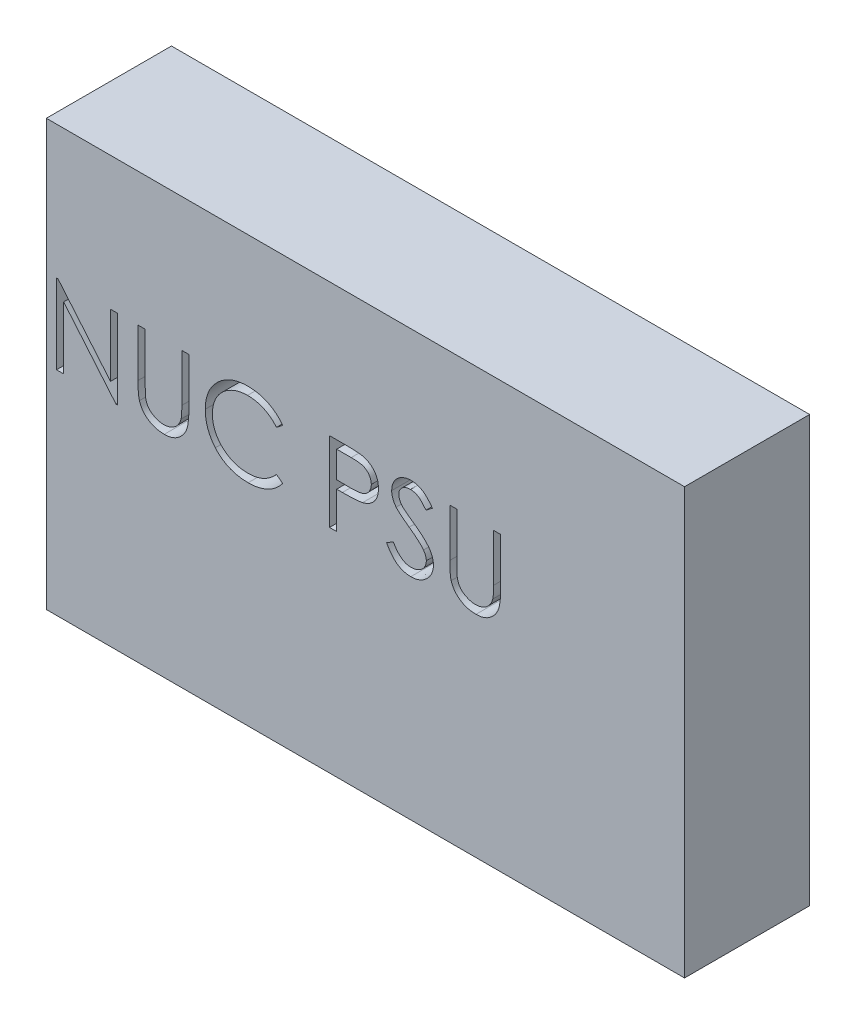
from build123d import *

# Parameters (mm, degrees)
SKETCH1_W               = 102
SKETCH1_H               = 68
BOSS_EXTRUDE1_DEPTH     = 20
CUT_EXTRUDE1_DEPTH      = 1
CUT_EXTRUDE1_DEPTH_BACK = 21


with BuildPart() as part:
    # Sketch1 → Boss-Extrude1 (new body)
    with BuildSketch(Plane.XY):
        Rectangle(SKETCH1_W, SKETCH1_H)
    extrude(amount=BOSS_EXTRUDE1_DEPTH)

    # Sketch2 → Cut-Extrude1 (cut, two sides)
    with BuildSketch(Plane.XY.offset(20)) as cut_extrude1_sk:
        Polygon((-49.371794872, 0), (-49.371794872, 12.7), (-49.132652244, 12.7), (-40.742307692, 2.704346955), (-40.742307692, 12.7), (-39.602564103, 12.7), (-39.602564103, 0), (-39.862059295, 0), (-48.232051282, 9.97275641), (-48.232051282, 0), align=None)
        with BuildLine():
            Line((-36.346153846, 12.7), (-35.206410256, 12.7))
            Line((-35.206410256, 12.7), (-35.206410256, 5.090685096))
            add(Edge.make_bspline(
                [(-35.206410256, 5.090685096), (-35.20657987, 4.982986426), (-35.206901742, 4.778609641), (-35.204751763, 4.487713236), (-35.198730626, 4.229096028), (-35.194934561, 4.001761138), (-35.186489665, 3.80675174), (-35.179602467, 3.643011327), (-35.170746732, 3.511315221), (-35.160103706, 3.434458718), (-35.155528846, 3.401422276)],
                knots=[0, 0, 0, 0, 0.000323097, 0.000613132, 0.000872677, 0.001099157, 0.001295199, 0.001458198, 0.00159088, 0.001690911, 0.001690911, 0.001690911, 0.001690911], degree=3))
            add(Edge.make_bspline(
                [(-35.155528846, 3.401422276), (-35.136742067, 3.282235449), (-35.100227077, 3.050577546), (-35.007167363, 2.720710352), (-34.877201002, 2.423416203), (-34.72319339, 2.14941809), (-34.520237915, 1.906342412), (-34.277110801, 1.682417272), (-33.982551469, 1.486576723), (-33.655034414, 1.307503778), (-33.302027981, 1.163576193), (-32.9413071, 1.054743128), (-32.578294005, 0.988416835), (-32.335266206, 0.980736822), (-32.214583333, 0.976923077)],
                knots=[0, 0, 0, 0, 0.000361804, 0.000703222, 0.001024581, 0.001333516, 0.001642649, 0.00197037, 0.002321784, 0.002700859, 0.003088736, 0.003463025, 0.003829839, 0.00419167, 0.00419167, 0.00419167, 0.00419167], degree=3))
            add(Edge.make_bspline(
                [(-32.214583333, 0.976923077), (-32.110974047, 0.980819619), (-31.904353894, 0.988590199), (-31.597353417, 1.036710249), (-31.298358737, 1.123435158), (-31.005893412, 1.235339425), (-30.731751269, 1.383194969), (-30.475779351, 1.553994873), (-30.247310218, 1.75433148), (-30.038819769, 1.976038444), (-29.85726443, 2.226191433), (-29.699889145, 2.499343534), (-29.570980771, 2.79960545), (-29.507322838, 3.010622925), (-29.474619391, 3.119030449)],
                knots=[0, 0, 0, 0, 0.000310887, 0.000619979, 0.000929248, 0.001243418, 0.001557536, 0.001861656, 0.002164646, 0.002467059, 0.002772877, 0.003089693, 0.003411052, 0.003750569, 0.003750569, 0.003750569, 0.003750569], degree=3))
            add(Edge.make_bspline(
                [(-29.474619391, 3.119030449), (-29.463733222, 3.163838133), (-29.439474451, 3.26368771), (-29.416806602, 3.432493536), (-29.393197209, 3.631663514), (-29.37681577, 3.862628663), (-29.360845627, 4.124615049), (-29.351291334, 4.418987469), (-29.346875243, 4.744677013), (-29.345559232, 4.971960429), (-29.344871795, 5.090685096)],
                knots=[0, 0, 0, 0, 0.000138249, 0.000308074, 0.000510355, 0.000740013, 0.001002497, 0.001297784, 0.001623465, 0.001979644, 0.001979644, 0.001979644, 0.001979644], degree=3))
            Line((-29.344871795, 5.090685096), (-29.344871795, 12.7))
            Line((-29.344871795, 12.7), (-28.205128205, 12.7))
            Line((-28.205128205, 12.7), (-28.205128205, 5.029627404))
            add(Edge.make_bspline(
                [(-28.205128205, 5.029627404), (-28.206050299, 4.891384715), (-28.207849822, 4.621595701), (-28.223454771, 4.226257913), (-28.248335884, 3.851234238), (-28.283489804, 3.496474265), (-28.330069786, 3.163247458), (-28.381868444, 2.848633014), (-28.447834178, 2.554889297), (-28.524881091, 2.279725953), (-28.612959394, 2.017795662), (-28.727045846, 1.76920726), (-28.855586175, 1.526403581), (-29.008039344, 1.293057015), (-29.179349218, 1.068134379), (-29.373302459, 0.852999736), (-29.583484415, 0.644215196), (-29.813389102, 0.447136356), (-30.059226723, 0.266402014), (-30.320265997, 0.107478674), (-30.594501705, -0.026864167), (-30.881220991, -0.137448235), (-31.180546213, -0.220595495), (-31.492484918, -0.282553918), (-31.817747134, -0.317759397), (-32.038961744, -0.322991544), (-32.150981571, -0.325641026)],
                knots=[0, 0, 0, 0, 0.000414715, 0.000809341, 0.001186722, 0.001542137, 0.001878541, 0.00219599, 0.002498424, 0.002781137, 0.003053079, 0.003326374, 0.003600686, 0.003876597, 0.004161544, 0.004448032, 0.004744861, 0.005049778, 0.005355596, 0.005659269, 0.00596533, 0.006270545, 0.006579814, 0.006896139, 0.007223722, 0.007559781, 0.007559781, 0.007559781, 0.007559781], degree=3))
            add(Edge.make_bspline(
                [(-32.150981571, -0.325641026), (-32.273152314, -0.322793449), (-32.512850876, -0.317206513), (-32.866049006, -0.285192534), (-33.204646233, -0.224891503), (-33.532218701, -0.148111136), (-33.844306676, -0.042215861), (-34.14509146, 0.081511621), (-34.429421532, 0.233466251), (-34.70190957, 0.402533706), (-34.955273685, 0.59276025), (-35.187855691, 0.800097452), (-35.400039564, 1.021223965), (-35.588248833, 1.258533863), (-35.755601757, 1.510181486), (-35.899765675, 1.776878727), (-36.023548018, 2.058522332), (-36.087434704, 2.254295373), (-36.119731571, 2.353265224)],
                knots=[0, 0, 0, 0, 0.000366567, 0.000719203, 0.001062587, 0.001397642, 0.001727489, 0.002050195, 0.002372249, 0.002693427, 0.003011436, 0.003321374, 0.003627277, 0.003929636, 0.004228811, 0.00453276, 0.004838091, 0.005150256, 0.005150256, 0.005150256, 0.005150256], degree=3))
            add(Edge.make_bspline(
                [(-36.119731571, 2.353265224), (-36.138517259, 2.420874852), (-36.179263835, 2.567521639), (-36.222898486, 2.81022404), (-36.259580011, 3.08967817), (-36.294071608, 3.405903157), (-36.314424113, 3.759144101), (-36.33226739, 4.149247882), (-36.34627955, 4.5766862), (-36.346196919, 4.874426871), (-36.346153846, 5.029627404)],
                knots=[0, 0, 0, 0, 0.000210421, 0.000456408, 0.000738845, 0.001056039, 0.001410405, 0.001800055, 0.002227648, 0.00269322, 0.00269322, 0.00269322, 0.00269322], degree=3))
            Line((-36.346153846, 5.029627404), (-36.346153846, 12.7))
        make_face()
        with BuildLine():
            Line((-13.225641026, 10.36963141), (-14.222916667, 9.606410256))
            add(Edge.make_bspline(
                [(-14.222916667, 9.606410256), (-14.294058033, 9.691195347), (-14.435381626, 9.859622441), (-14.662745018, 10.096131074), (-14.899696693, 10.317710737), (-15.146146076, 10.525416986), (-15.406529167, 10.711986393), (-15.674538351, 10.887141538), (-15.954656972, 11.044141615), (-16.342013266, 11.234507308), (-16.848735458, 11.433157642), (-17.486619589, 11.599720795), (-18.152502717, 11.705751919), (-18.60679115, 11.717235772), (-18.837860577, 11.723076923)],
                knots=[0, 0, 0, 0, 0.00033196, 0.000659444, 0.000983431, 0.001304932, 0.001625525, 0.001943778, 0.002265016, 0.002588143, 0.003238217, 0.003893566, 0.004562806, 0.005255583, 0.005255583, 0.005255583, 0.005255583], degree=3))
            add(Edge.make_bspline(
                [(-18.837860577, 11.723076923), (-18.965162835, 11.721611116), (-19.218585865, 11.718693107), (-19.594681754, 11.680197138), (-19.963754826, 11.626090747), (-20.325565003, 11.545807432), (-20.679651738, 11.444306785), (-21.028329883, 11.323020283), (-21.366551202, 11.172961293), (-21.698994524, 11.007105607), (-22.017507661, 10.819771736), (-22.318878834, 10.615434716), (-22.602008889, 10.396381138), (-22.867121796, 10.16178998), (-23.11448858, 9.912717724), (-23.342316822, 9.64650997), (-23.549818168, 9.364017797), (-23.741105659, 9.06896629), (-23.912420434, 8.762214875), (-24.055857425, 8.442628191), (-24.182876011, 8.115679017), (-24.283384692, 7.777673376), (-24.362939367, 7.430989626), (-24.417831174, 7.074697338), (-24.455889341, 6.709540843), (-24.45879284, 6.46203848), (-24.46025641, 6.337279647)],
                knots=[0, 0, 0, 0, 0.000381746, 0.00075995, 0.001133062, 0.001500343, 0.001870765, 0.002237676, 0.002606812, 0.002979993, 0.003351741, 0.00371443, 0.004071661, 0.004424911, 0.004775707, 0.005123948, 0.005475039, 0.005826461, 0.006178335, 0.006527846, 0.006876532, 0.007229865, 0.007584733, 0.007942761, 0.008310834, 0.008684951, 0.008684951, 0.008684951, 0.008684951], degree=3))
            add(Edge.make_bspline(
                [(-24.46025641, 6.337279647), (-24.45567781, 6.149568858), (-24.446688335, 5.781023622), (-24.36668438, 5.241198835), (-24.245108763, 4.72405239), (-24.062897955, 4.232816962), (-23.838220258, 3.761435206), (-23.55431861, 3.317882795), (-23.225510032, 2.895456975), (-22.847142852, 2.504141136), (-22.432013177, 2.146677047), (-21.986613612, 1.831896366), (-21.512053482, 1.569496649), (-21.013572567, 1.351143929), (-20.487334954, 1.183298089), (-19.934286957, 1.06513684), (-19.355631431, 0.988058071), (-18.96022818, 0.980678689), (-18.758994391, 0.976923077)],
                knots=[0, 0, 0, 0, 0.000562815, 0.001105012, 0.001633818, 0.00215373, 0.002673724, 0.003197432, 0.003730267, 0.004277248, 0.00482748, 0.005371661, 0.005910344, 0.006451519, 0.007001839, 0.007564217, 0.008146414, 0.008749794, 0.008749794, 0.008749794, 0.008749794], degree=3))
            add(Edge.make_bspline(
                [(-18.758994391, 0.976923077), (-18.53727892, 0.983050935), (-18.100889833, 0.995112025), (-17.460925852, 1.097289872), (-16.848293216, 1.262962888), (-16.262958974, 1.494821063), (-15.706573257, 1.796229394), (-15.178265376, 2.161618835), (-14.677589391, 2.594465071), (-14.376522167, 2.924966708), (-14.222916667, 3.093589744)],
                knots=[0, 0, 0, 0, 0.000664826, 0.001308536, 0.001938654, 0.00256556, 0.003192755, 0.00383282, 0.004489298, 0.005173128, 0.005173128, 0.005173128, 0.005173128], degree=3))
            Line((-14.222916667, 3.093589744), (-13.225641026, 2.338000801))
            add(Edge.make_bspline(
                [(-13.225641026, 2.338000801), (-13.305898167, 2.23444699), (-13.466028023, 2.027835384), (-13.725318542, 1.736563752), (-13.998467593, 1.462591966), (-14.287504026, 1.208128883), (-14.58910287, 0.96808268), (-14.908679546, 0.749273177), (-15.242032892, 0.548646254), (-15.58803343, 0.364942843), (-15.94631354, 0.201957403), (-16.316443918, 0.06242516), (-16.696829149, -0.057770867), (-17.087486622, -0.156656466), (-17.489226654, -0.233840114), (-17.900599517, -0.285437219), (-18.322493064, -0.320786452), (-18.607123364, -0.324008318), (-18.751362179, -0.325641026)],
                knots=[0, 0, 0, 0, 0.00039295, 0.000784017, 0.001168988, 0.001552873, 0.001938676, 0.002324679, 0.002713864, 0.003105353, 0.00349929, 0.003893826, 0.004291304, 0.004695459, 0.005102104, 0.005517692, 0.005938765, 0.006371376, 0.006371376, 0.006371376, 0.006371376], degree=3))
            add(Edge.make_bspline(
                [(-18.751362179, -0.325641026), (-18.887954914, -0.324690367), (-19.158050133, -0.322810557), (-19.556825603, -0.292358978), (-19.945044939, -0.25081279), (-20.321598581, -0.188255743), (-20.688541405, -0.114434852), (-21.042546954, -0.015479149), (-21.387098718, 0.095370684), (-21.720812411, 0.225654493), (-22.043971893, 0.372670355), (-22.355534866, 0.538828297), (-22.655358035, 0.722731064), (-22.946389133, 0.920324958), (-23.224328937, 1.137956882), (-23.491586015, 1.372604385), (-23.749659, 1.623476595), (-23.909325885, 1.804378492), (-23.989603365, 1.895332532)],
                knots=[0, 0, 0, 0, 0.000409666, 0.000810065, 0.001199174, 0.001580615, 0.001954827, 0.00232143, 0.002682661, 0.003040299, 0.003395496, 0.003747176, 0.004098847, 0.004450261, 0.004801913, 0.005157073, 0.005516877, 0.005880706, 0.005880706, 0.005880706, 0.005880706], degree=3))
            add(Edge.make_bspline(
                [(-23.989603365, 1.895332532), (-24.118184129, 2.053324846), (-24.373793316, 2.367402052), (-24.700820797, 2.876439756), (-24.980756211, 3.407910114), (-25.207091695, 3.964605284), (-25.384030755, 4.545276089), (-25.506608235, 5.150215241), (-25.5862612, 5.778857774), (-25.595369962, 6.206436979), (-25.6, 6.423778045)],
                knots=[0, 0, 0, 0, 0.000610709, 0.001214046, 0.001811469, 0.002410515, 0.003014109, 0.003629806, 0.004260284, 0.004912063, 0.004912063, 0.004912063, 0.004912063], degree=3))
            add(Edge.make_bspline(
                [(-25.6, 6.423778045), (-25.594356869, 6.652216405), (-25.583254361, 7.101654617), (-25.488926761, 7.76123439), (-25.337184272, 8.39315518), (-25.121658419, 8.996237339), (-24.848407573, 9.573652928), (-24.510853859, 10.120991014), (-24.112918801, 10.641751972), (-23.657723341, 11.12803407), (-23.158550438, 11.572676864), (-22.623993599, 11.963859375), (-22.055099106, 12.28940579), (-21.45813433, 12.561534722), (-20.828629143, 12.770701774), (-20.167926632, 12.917126194), (-19.477268284, 13.008265445), (-19.006053196, 13.019786913), (-18.766626603, 13.025641026)],
                knots=[0, 0, 0, 0, 0.000685036, 0.001347765, 0.001994424, 0.002631723, 0.003265569, 0.003907406, 0.004557186, 0.005228594, 0.005902557, 0.006560016, 0.007211953, 0.007865497, 0.008525192, 0.009197944, 0.009893113, 0.01061119, 0.01061119, 0.01061119, 0.01061119], degree=3))
            add(Edge.make_bspline(
                [(-18.766626603, 13.025641026), (-18.620705519, 13.023891553), (-18.331869428, 13.020428647), (-17.904595518, 12.986660646), (-17.488607646, 12.930368418), (-17.083619226, 12.85374725), (-16.687660018, 12.758652112), (-16.303756287, 12.634771601), (-15.929655338, 12.493124759), (-15.567716557, 12.329989754), (-15.219676503, 12.146867578), (-14.885643576, 11.94578803), (-14.568271089, 11.727000393), (-14.265325839, 11.492365442), (-13.981875587, 11.236919241), (-13.709872508, 10.967687964), (-13.458553738, 10.676916659), (-13.303420717, 10.472247328), (-13.225641026, 10.36963141)],
                knots=[0, 0, 0, 0, 0.000437698, 0.00086638, 0.001284824, 0.001696468, 0.002102476, 0.002505573, 0.002905769, 0.003302024, 0.003695764, 0.004084948, 0.004470952, 0.004851611, 0.005233595, 0.005614968, 0.005999089, 0.006385327, 0.006385327, 0.006385327, 0.006385327], degree=3))
        make_face()
        with BuildLine():
            Line((-5.735897436, 12.7), (-3.245252404, 12.7))
            add(Edge.make_bspline(
                [(-3.245252404, 12.7), (-3.073944259, 12.699811691), (-2.745710245, 12.699450882), (-2.2750299, 12.688511661), (-1.847548874, 12.673900522), (-1.46418892, 12.653646223), (-1.123770507, 12.629710024), (-0.82783402, 12.596138339), (-0.574053344, 12.561085266), (-0.421992799, 12.525447591), (-0.352644231, 12.509194712)],
                knots=[0, 0, 0, 0, 0.000513909, 0.000984672, 0.001412348, 0.001797041, 0.002136358, 0.002435846, 0.002690583, 0.002904164, 0.002904164, 0.002904164, 0.002904164], degree=3))
            add(Edge.make_bspline(
                [(-0.352644231, 12.509194712), (-0.264856265, 12.485166494), (-0.091348948, 12.437676253), (0.158663408, 12.342557885), (0.396530219, 12.229774028), (0.623067588, 12.101235732), (0.835491718, 11.951428113), (1.036971924, 11.786423843), (1.225730138, 11.602413294), (1.400704903, 11.401460324), (1.561395454, 11.18693842), (1.699751732, 10.955645185), (1.815601956, 10.711473885), (1.914964112, 10.454594355), (1.986477647, 10.182849467), (2.040350683, 9.898127396), (2.074544989, 9.600458663), (2.077819999, 9.39704143), (2.079487179, 9.293489583)],
                knots=[0, 0, 0, 0, 0.000272928, 0.000539425, 0.000801167, 0.00106213, 0.001319735, 0.001580002, 0.001842671, 0.002109519, 0.002378686, 0.002645705, 0.002916526, 0.003188682, 0.003470718, 0.003758119, 0.004057607, 0.004368151, 0.004368151, 0.004368151, 0.004368151], degree=3))
            add(Edge.make_bspline(
                [(2.079487179, 9.293489583), (2.07795801, 9.189067365), (2.074966086, 8.984758241), (2.039056708, 8.685862696), (1.990687155, 8.400227394), (1.916312137, 8.128485674), (1.818900694, 7.872251307), (1.704629531, 7.627608551), (1.566803578, 7.398719455), (1.408435196, 7.184753057), (1.232262268, 6.985508519), (1.039030178, 6.802429693), (0.829519031, 6.636588236), (0.604394665, 6.487612361), (0.361462356, 6.358956718), (0.104406542, 6.243723069), (-0.1690071, 6.14694522), (-0.358209937, 6.09603614), (-0.454407051, 6.070152244)],
                knots=[0, 0, 0, 0, 0.000313086, 0.000612574, 0.000902017, 0.001181599, 0.001456135, 0.001723565, 0.001990583, 0.002256192, 0.00252113, 0.002787469, 0.003053674, 0.003321805, 0.003596116, 0.003877417, 0.00416629, 0.004465075, 0.004465075, 0.004465075, 0.004465075], degree=3))
            add(Edge.make_bspline(
                [(-0.454407051, 6.070152244), (-0.533971949, 6.053232284), (-0.708343048, 6.016151208), (-0.995518069, 5.974754807), (-1.329874183, 5.939421228), (-1.710955028, 5.912928528), (-2.13841854, 5.89024862), (-2.612495959, 5.872221536), (-3.134117896, 5.862316067), (-3.497959268, 5.86180519), (-3.687920673, 5.861538462)],
                knots=[0, 0, 0, 0, 0.000243979, 0.000534694, 0.000869865, 0.0012525, 0.001680517, 0.002154049, 0.002675683, 0.00324556, 0.00324556, 0.00324556, 0.00324556], degree=3))
            Line((-3.687920673, 5.861538462), (-4.596153846, 5.861538462))
            Line((-4.596153846, 5.861538462), (-4.596153846, 0))
            Line((-4.596153846, 0), (-5.735897436, 0))
            Line((-5.735897436, 0), (-5.735897436, 12.7))
        make_face()
        with BuildLine():
            Line((-4.596153846, 11.397435897), (-4.596153846, 7.164102564))
            Line((-4.596153846, 7.164102564), (-2.372636218, 7.136117788))
            add(Edge.make_bspline(
                [(-2.372636218, 7.136117788), (-2.26406963, 7.136061678), (-2.05448407, 7.135953357), (-1.751729775, 7.150414025), (-1.470844646, 7.167107387), (-1.212691473, 7.191549166), (-0.977153882, 7.226097729), (-0.763839134, 7.260974606), (-0.574401279, 7.311431208), (-0.352698461, 7.379369202), (-0.105653172, 7.495238978), (0.163106218, 7.663422865), (0.390873775, 7.877801435), (0.587971594, 8.118839566), (0.744384351, 8.386987835), (0.858887523, 8.67389512), (0.926165437, 8.976619031), (0.935186769, 9.183767421), (0.93974359, 9.288401442)],
                knots=[0, 0, 0, 0, 0.000325651, 0.000628662, 0.000909076, 0.001169816, 0.001406195, 0.001623278, 0.001817645, 0.001993849, 0.002318305, 0.00263304, 0.002940915, 0.003252021, 0.003564434, 0.003868203, 0.004175604, 0.004489361, 0.004489361, 0.004489361, 0.004489361], degree=3))
            add(Edge.make_bspline(
                [(0.93974359, 9.288401442), (0.935161987, 9.390504048), (0.926054327, 9.593471392), (0.858360195, 9.890937181), (0.74460697, 10.174821022), (0.586921613, 10.439609075), (0.395546656, 10.679779878), (0.173117611, 10.88841231), (-0.079841937, 11.05613106), (-0.315148376, 11.164383254), (-0.524158394, 11.230478682), (-0.705702934, 11.276724245), (-0.910683381, 11.31364716), (-1.139166467, 11.343544784), (-1.389381264, 11.369138772), (-1.663477435, 11.386505032), (-1.960416655, 11.396670316), (-2.166557869, 11.397174525), (-2.273417468, 11.397435897)],
                knots=[0, 0, 0, 0, 0.000306146, 0.00060858, 0.000909985, 0.001220206, 0.001529716, 0.001828533, 0.002131234, 0.002436321, 0.002602057, 0.002788401, 0.002997974, 0.003226445, 0.00347959, 0.003752387, 0.004050218, 0.004370781, 0.004370781, 0.004370781, 0.004370781], degree=3))
            Line((-2.273417468, 11.397435897), (-4.596153846, 11.397435897))
        make_face(mode=Mode.SUBTRACT)
        with BuildLine():
            Line((3.382051282, 2.449939904), (4.455649038, 3.093589744))
            add(Edge.make_bspline(
                [(4.455649038, 3.093589744), (4.555500928, 2.926441832), (4.746813295, 2.606192885), (5.065951084, 2.173456567), (5.396633361, 1.805656741), (5.741308943, 1.504933051), (6.097873955, 1.268172805), (6.468656093, 1.100524707), (6.852405863, 0.995963882), (7.113568015, 0.983263568), (7.243950321, 0.976923077)],
                knots=[0, 0, 0, 0, 0.000583841, 0.001118616, 0.00161028, 0.002064766, 0.002487434, 0.002889373, 0.003281209, 0.003671854, 0.003671854, 0.003671854, 0.003671854], degree=3))
            add(Edge.make_bspline(
                [(7.243950321, 0.976923077), (7.355299786, 0.980024317), (7.576050362, 0.986172533), (7.901033358, 1.045248586), (8.216653041, 1.136006883), (8.516404383, 1.265985691), (8.796151327, 1.423242482), (9.041467051, 1.613184327), (9.253542947, 1.82584113), (9.427021734, 2.063086763), (9.560117862, 2.318237559), (9.662414796, 2.580133154), (9.719184063, 2.852887673), (9.727735712, 3.036531353), (9.732051282, 3.129206731)],
                knots=[0, 0, 0, 0, 0.000333749, 0.000661658, 0.000987706, 0.001317082, 0.001639577, 0.001947946, 0.002244774, 0.002537873, 0.002825803, 0.003105997, 0.003378925, 0.003656975, 0.003656975, 0.003656975, 0.003656975], degree=3))
            add(Edge.make_bspline(
                [(9.732051282, 3.129206731), (9.72670164, 3.234946385), (9.715826601, 3.449899652), (9.623909516, 3.767035535), (9.479313677, 4.080880004), (9.345917799, 4.275013167), (9.27666266, 4.375801282)],
                knots=[0, 0, 0, 0, 0.000316704, 0.000643812, 0.000983014, 0.001349263, 0.001349263, 0.001349263, 0.001349263], degree=3))
            add(Edge.make_bspline(
                [(9.27666266, 4.375801282), (9.219800717, 4.448542613), (9.100426181, 4.60125394), (8.895203207, 4.828566651), (8.65438902, 5.0630392), (8.386224693, 5.313624921), (8.08094177, 5.568669212), (7.748101932, 5.840334106), (7.379207358, 6.1182884), (7.120492042, 6.304697423), (6.986999199, 6.40088141)],
                knots=[0, 0, 0, 0, 0.00027693, 0.00058138, 0.000917785, 0.001285048, 0.001682135, 0.002110847, 0.002573875, 0.003067483, 0.003067483, 0.003067483, 0.003067483], degree=3))
            add(Edge.make_bspline(
                [(6.986999199, 6.40088141), (6.853380698, 6.496053714), (6.5979123, 6.678015911), (6.240648302, 6.948069742), (5.921172679, 7.194971783), (5.64090539, 7.421046341), (5.39996971, 7.626324078), (5.196467047, 7.808833743), (5.035581426, 7.973511235), (4.94611689, 8.080341247), (4.905949519, 8.128305288)],
                knots=[0, 0, 0, 0, 0.000492118, 0.000940893, 0.001343419, 0.001703394, 0.002021005, 0.002292935, 0.002523226, 0.002710868, 0.002710868, 0.002710868, 0.002710868], degree=3))
            add(Edge.make_bspline(
                [(4.905949519, 8.128305288), (4.849806284, 8.203057622), (4.739393076, 8.350068119), (4.593647856, 8.579846888), (4.469771466, 8.815062737), (4.372662432, 9.056347731), (4.290888152, 9.300314473), (4.235886518, 9.550146136), (4.201446306, 9.804721695), (4.197919384, 9.976039254), (4.196153846, 10.061798878)],
                knots=[0, 0, 0, 0, 0.000280379, 0.000551403, 0.000815399, 0.001076659, 0.001330888, 0.001586412, 0.00184296, 0.002100112, 0.002100112, 0.002100112, 0.002100112], degree=3))
            add(Edge.make_bspline(
                [(4.196153846, 10.061798878), (4.20088989, 10.19616406), (4.210260749, 10.462022463), (4.289510626, 10.850391476), (4.414597983, 11.22118219), (4.589839433, 11.570723687), (4.815744685, 11.889914532), (5.077168649, 12.182426327), (5.388541756, 12.428329469), (5.730181275, 12.643184652), (6.104128682, 12.811354152), (6.495981389, 12.938212566), (6.906362193, 13.010091872), (7.184322139, 13.020407048), (7.325360577, 13.025641026)],
                knots=[0, 0, 0, 0, 0.000402767, 0.000796926, 0.001183901, 0.001574148, 0.001965141, 0.002354126, 0.002746681, 0.003151188, 0.003562179, 0.00397332, 0.004384052, 0.004807133, 0.004807133, 0.004807133, 0.004807133], degree=3))
            add(Edge.make_bspline(
                [(7.325360577, 13.025641026), (7.475017741, 13.020479196), (7.772638074, 13.010213963), (8.210422371, 12.920960064), (8.631919827, 12.773274769), (8.970985388, 12.605675924), (9.236352837, 12.438284787), (9.438728181, 12.285812853), (9.643805789, 12.110280316), (9.853239873, 11.911219624), (10.063481695, 11.68680427), (10.277652507, 11.438571198), (10.49625314, 11.16803741), (10.636881546, 10.974908507), (10.708974359, 10.875901442)],
                knots=[0, 0, 0, 0, 0.00044863, 0.000892182, 0.001333892, 0.001785577, 0.002023431, 0.002274276, 0.002544978, 0.002832897, 0.003140645, 0.00346709, 0.003816333, 0.004183702, 0.004183702, 0.004183702, 0.004183702], degree=3))
            Line((10.708974359, 10.875901442), (9.678625801, 10.094871795))
            add(Edge.make_bspline(
                [(9.678625801, 10.094871795), (9.616410561, 10.175022186), (9.496598554, 10.329373099), (9.31470013, 10.545531873), (9.143255036, 10.742985956), (8.974343585, 10.914490849), (8.816886694, 11.06943859), (8.664061998, 11.202098279), (8.51806878, 11.313769725), (8.334038847, 11.432944928), (8.102834555, 11.551078527), (7.812604952, 11.651042325), (7.509306183, 11.711113549), (7.302732949, 11.719056084), (7.198157051, 11.723076923)],
                knots=[0, 0, 0, 0, 0.000304354, 0.000586115, 0.000847462, 0.001088545, 0.001308044, 0.001510038, 0.001695249, 0.001858961, 0.002167298, 0.002471418, 0.002777268, 0.00309085, 0.00309085, 0.00309085, 0.00309085], degree=3))
            add(Edge.make_bspline(
                [(7.198157051, 11.723076923), (7.066960527, 11.718680183), (6.813960389, 11.710201485), (6.454767247, 11.617600395), (6.131483576, 11.471797645), (5.853707126, 11.267454724), (5.622432952, 11.025352837), (5.455136001, 10.746755277), (5.354442547, 10.439116273), (5.34215519, 10.224516549), (5.335897436, 10.115224359)],
                knots=[0, 0, 0, 0, 0.000392785, 0.000757449, 0.001104647, 0.001450678, 0.001785453, 0.002102647, 0.002418029, 0.002745345, 0.002745345, 0.002745345, 0.002745345], degree=3))
            add(Edge.make_bspline(
                [(5.335897436, 10.115224359), (5.337323924, 10.04718328), (5.340179233, 9.910989861), (5.38000207, 9.709780415), (5.431162492, 9.509079269), (5.512234327, 9.309788754), (5.624158715, 9.108423509), (5.771134639, 8.901516061), (5.956240085, 8.687242718), (6.098033816, 8.547878819), (6.172896635, 8.474298878)],
                knots=[0, 0, 0, 0, 0.00020378, 0.000407893, 0.000613397, 0.00082457, 0.001051163, 0.001303142, 0.001584604, 0.001899422, 0.001899422, 0.001899422, 0.001899422], degree=3))
            add(Edge.make_bspline(
                [(6.172896635, 8.474298878), (6.200696472, 8.449490242), (6.266742521, 8.3905506), (6.387486594, 8.29405861), (6.546936177, 8.175031408), (6.740927592, 8.027757431), (6.973037733, 7.856918983), (7.243292123, 7.664700447), (7.548678256, 7.444861782), (7.765383494, 7.29116442), (7.879967949, 7.209895833)],
                knots=[0, 0, 0, 0, 0.000111766, 0.000265529, 0.000463461, 0.000708709, 0.000996201, 0.001328024, 0.001703617, 0.002125051, 0.002125051, 0.002125051, 0.002125051], degree=3))
            add(Edge.make_bspline(
                [(7.879967949, 7.209895833), (8.017802548, 7.109597186), (8.284700147, 6.915382756), (8.664457652, 6.623588717), (9.008786612, 6.338209671), (9.318895951, 6.061068068), (9.597849304, 5.794266131), (9.842551891, 5.534594019), (10.055497074, 5.283912084), (10.284747381, 4.962520167), (10.51900004, 4.567800232), (10.72017351, 4.084190624), (10.847022371, 3.598701118), (10.863610441, 3.272395168), (10.871794872, 3.111398237)],
                knots=[0, 0, 0, 0, 0.000511383, 0.000990223, 0.001436481, 0.001852691, 0.002237729, 0.002594081, 0.002922749, 0.00322352, 0.00377766, 0.004295477, 0.004790951, 0.0052735, 0.0052735, 0.0052735, 0.0052735], degree=3))
            add(Edge.make_bspline(
                [(10.871794872, 3.111398237), (10.869410399, 2.997539598), (10.864687759, 2.772033378), (10.810401014, 2.440907813), (10.730863944, 2.119304372), (10.610985981, 1.811198335), (10.464670521, 1.510953053), (10.279010135, 1.226444386), (10.063807965, 0.951375454), (9.81694259, 0.693081071), (9.546810316, 0.455967732), (9.261300909, 0.24504228), (8.959947062, 0.069171506), (8.64438357, -0.074341549), (8.314537948, -0.186586027), (7.970521132, -0.267912723), (7.611766049, -0.317826303), (7.367924301, -0.323007037), (7.243950321, -0.325641026)],
                knots=[0, 0, 0, 0, 0.000341247, 0.000675867, 0.001004131, 0.001333458, 0.001665681, 0.002004415, 0.002350493, 0.00271219, 0.00307453, 0.00342767, 0.003775427, 0.004119254, 0.004466004, 0.00481897, 0.005178405, 0.005550153, 0.005550153, 0.005550153, 0.005550153], degree=3))
            add(Edge.make_bspline(
                [(7.243950321, -0.325641026), (7.14802779, -0.323786167), (6.957390775, -0.320099809), (6.67541637, -0.287510591), (6.399138432, -0.241401958), (6.132023751, -0.168198904), (5.870630857, -0.079382445), (5.616096606, 0.029976648), (5.36829764, 0.161030493), (5.125845267, 0.31087244), (4.88935612, 0.485253398), (4.661048336, 0.688357228), (4.433431006, 0.914582346), (4.213222453, 1.170072105), (3.995968473, 1.450698863), (3.785952529, 1.759088185), (3.57882744, 2.093560297), (3.448868456, 2.328927894), (3.382051282, 2.449939904)],
                knots=[0, 0, 0, 0, 0.00028766, 0.000571697, 0.000850676, 0.001127139, 0.001401486, 0.001678416, 0.001957221, 0.002241725, 0.002532773, 0.002837436, 0.003157645, 0.003494857, 0.003848519, 0.004221814, 0.00461365, 0.005028294, 0.005028294, 0.005028294, 0.005028294], degree=3))
        make_face()
        with BuildLine():
            Line((13.476923077, 12.7), (14.616666667, 12.7))
            Line((14.616666667, 12.7), (14.616666667, 5.090685096))
            add(Edge.make_bspline(
                [(14.616666667, 5.090685096), (14.616497053, 4.982986426), (14.616175181, 4.778609641), (14.61832516, 4.487713236), (14.624346297, 4.229096028), (14.628142362, 4.001761138), (14.636587258, 3.80675174), (14.643474456, 3.643011327), (14.652330191, 3.511315221), (14.662973217, 3.434458718), (14.667548077, 3.401422276)],
                knots=[0, 0, 0, 0, 0.000323097, 0.000613132, 0.000872677, 0.001099157, 0.001295199, 0.001458198, 0.00159088, 0.001690911, 0.001690911, 0.001690911, 0.001690911], degree=3))
            add(Edge.make_bspline(
                [(14.667548077, 3.401422276), (14.686334856, 3.282235449), (14.722849846, 3.050577546), (14.81590956, 2.720710352), (14.945875921, 2.423416203), (15.099883533, 2.14941809), (15.302839009, 1.906342412), (15.545966122, 1.682417272), (15.840525454, 1.486576723), (16.168042509, 1.307503778), (16.521048942, 1.163576193), (16.881769823, 1.054743128), (17.244782918, 0.988416835), (17.487810717, 0.980736822), (17.60849359, 0.976923077)],
                knots=[0, 0, 0, 0, 0.000361804, 0.000703222, 0.001024581, 0.001333516, 0.001642649, 0.00197037, 0.002321784, 0.002700859, 0.003088736, 0.003463025, 0.003829839, 0.00419167, 0.00419167, 0.00419167, 0.00419167], degree=3))
            add(Edge.make_bspline(
                [(17.60849359, 0.976923077), (17.712102876, 0.980819619), (17.918723029, 0.988590199), (18.225723507, 1.036710249), (18.524718187, 1.123435158), (18.817183511, 1.235339425), (19.091325654, 1.383194969), (19.347297572, 1.553994873), (19.575766705, 1.75433148), (19.784257154, 1.976038444), (19.965812493, 2.226191433), (20.123187778, 2.499343534), (20.252096152, 2.79960545), (20.315754085, 3.010622925), (20.348457532, 3.119030449)],
                knots=[0, 0, 0, 0, 0.000310887, 0.000619979, 0.000929248, 0.001243418, 0.001557536, 0.001861656, 0.002164646, 0.002467059, 0.002772877, 0.003089693, 0.003411052, 0.003750569, 0.003750569, 0.003750569, 0.003750569], degree=3))
            add(Edge.make_bspline(
                [(20.348457532, 3.119030449), (20.359343701, 3.163838133), (20.383602472, 3.26368771), (20.406270321, 3.432493536), (20.429879714, 3.631663514), (20.446261153, 3.862628663), (20.462231296, 4.124615049), (20.471785589, 4.418987469), (20.47620168, 4.744677013), (20.477517691, 4.971960429), (20.478205128, 5.090685096)],
                knots=[0, 0, 0, 0, 0.000138249, 0.000308074, 0.000510355, 0.000740013, 0.001002497, 0.001297784, 0.001623465, 0.001979644, 0.001979644, 0.001979644, 0.001979644], degree=3))
            Line((20.478205128, 5.090685096), (20.478205128, 12.7))
            Line((20.478205128, 12.7), (21.617948718, 12.7))
            Line((21.617948718, 12.7), (21.617948718, 5.029627404))
            add(Edge.make_bspline(
                [(21.617948718, 5.029627404), (21.617026624, 4.891384715), (21.615227102, 4.621595701), (21.599622153, 4.226257913), (21.574741039, 3.851234238), (21.53958712, 3.496474265), (21.493007137, 3.163247458), (21.441208479, 2.848633014), (21.375242745, 2.554889297), (21.298195832, 2.279725953), (21.210117529, 2.017795662), (21.096031077, 1.76920726), (20.967490749, 1.526403581), (20.815037579, 1.293057015), (20.643727705, 1.068134379), (20.449774464, 0.852999736), (20.239592508, 0.644215196), (20.009687821, 0.447136356), (19.763850201, 0.266402014), (19.502810926, 0.107478674), (19.228575218, -0.026864167), (18.941855932, -0.137448235), (18.64253071, -0.220595495), (18.330592005, -0.282553918), (18.005329789, -0.317759397), (17.784115179, -0.322991544), (17.672095353, -0.325641026)],
                knots=[0, 0, 0, 0, 0.000414715, 0.000809341, 0.001186722, 0.001542137, 0.001878541, 0.00219599, 0.002498424, 0.002781137, 0.003053079, 0.003326374, 0.003600686, 0.003876597, 0.004161544, 0.004448032, 0.004744861, 0.005049778, 0.005355596, 0.005659269, 0.00596533, 0.006270545, 0.006579814, 0.006896139, 0.007223722, 0.007559781, 0.007559781, 0.007559781, 0.007559781], degree=3))
            add(Edge.make_bspline(
                [(17.672095353, -0.325641026), (17.549924609, -0.322793449), (17.310226047, -0.317206513), (16.957027917, -0.285192534), (16.61843069, -0.224891503), (16.290858222, -0.148111136), (15.978770247, -0.042215861), (15.677985463, 0.081511621), (15.393655391, 0.233466251), (15.121167353, 0.402533706), (14.867803238, 0.59276025), (14.635221233, 0.800097452), (14.423037359, 1.021223965), (14.23482809, 1.258533863), (14.067475166, 1.510181486), (13.923311248, 1.776878727), (13.799528905, 2.058522332), (13.735642219, 2.254295373), (13.703345353, 2.353265224)],
                knots=[0, 0, 0, 0, 0.000366567, 0.000719203, 0.001062587, 0.001397642, 0.001727489, 0.002050195, 0.002372249, 0.002693427, 0.003011436, 0.003321374, 0.003627277, 0.003929636, 0.004228811, 0.00453276, 0.004838091, 0.005150256, 0.005150256, 0.005150256, 0.005150256], degree=3))
            add(Edge.make_bspline(
                [(13.703345353, 2.353265224), (13.684559664, 2.420874852), (13.643813088, 2.567521639), (13.600178437, 2.81022404), (13.563496912, 3.08967817), (13.529005315, 3.405903157), (13.50865281, 3.759144101), (13.490809533, 4.149247882), (13.476797373, 4.5766862), (13.476880004, 4.874426871), (13.476923077, 5.029627404)],
                knots=[0, 0, 0, 0, 0.000210421, 0.000456408, 0.000738845, 0.001056039, 0.001410405, 0.001800055, 0.002227648, 0.00269322, 0.00269322, 0.00269322, 0.00269322], degree=3))
            Line((13.476923077, 5.029627404), (13.476923077, 12.7))
        make_face()
    extrude(amount=CUT_EXTRUDE1_DEPTH, mode=Mode.SUBTRACT)
    extrude(cut_extrude1_sk.sketch, amount=-CUT_EXTRUDE1_DEPTH_BACK, mode=Mode.SUBTRACT)


solid = part.part
